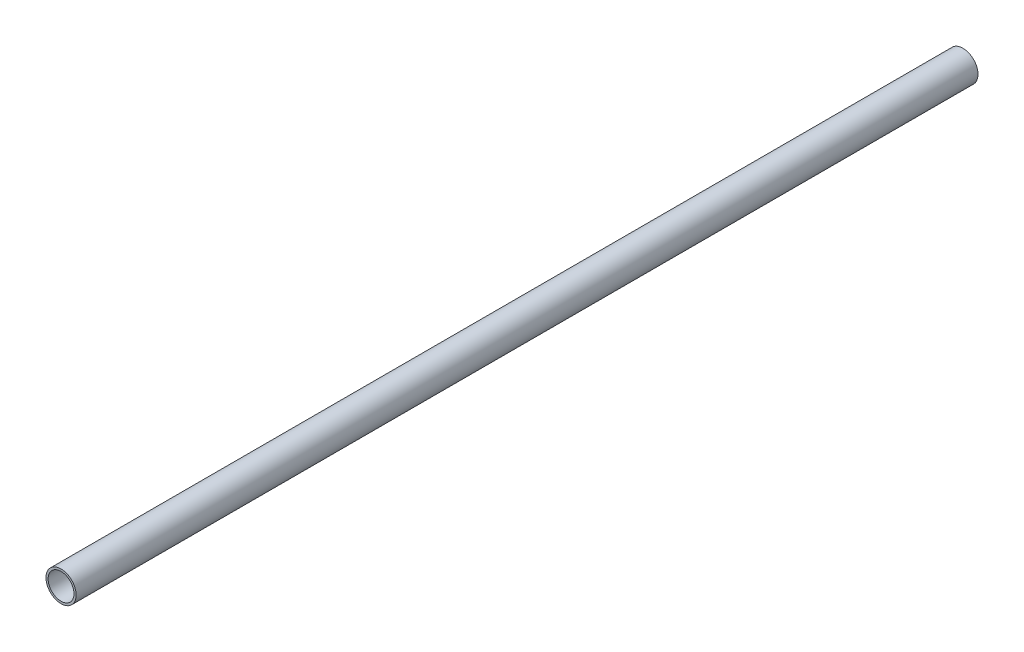
from build123d import *

# Parameters (mm, degrees)
SKETCH1_R           = 11.1125
SKETCH1_R_2         = 9.525
BOSS_EXTRUDE1_DEPTH = 332.359
SCALE1_SCALE        = 0.35


with BuildPart() as part:
    # Sketch1 → Boss-Extrude1 (new body, symmetric)
    with BuildSketch(Plane.XY):
        Circle(SKETCH1_R)
        Circle(SKETCH1_R_2, mode=Mode.SUBTRACT)
    extrude(amount=BOSS_EXTRUDE1_DEPTH, both=True)


with BuildPart() as part_1:
    # Scale1: scaled about (0, 0, 0)
    add(part.part.scale(SCALE1_SCALE))


solid = part_1.part
